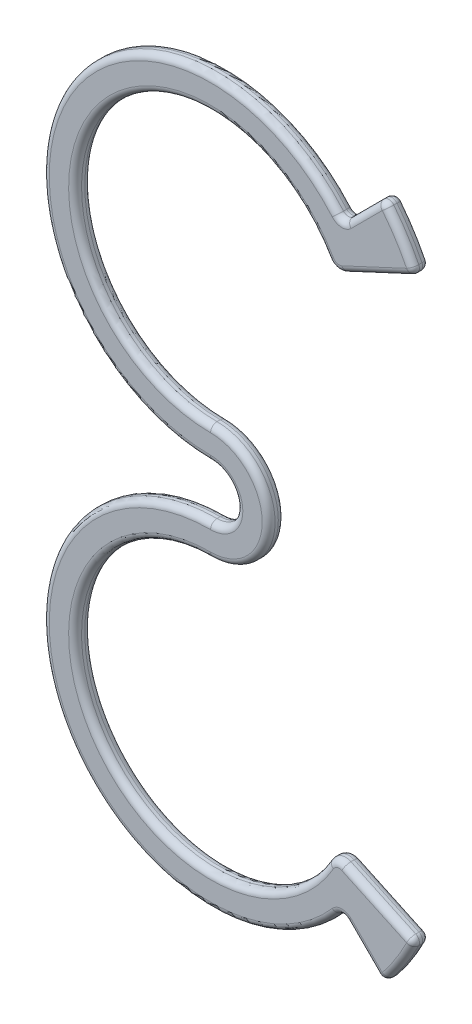
from build123d import *

# Parameters (mm, degrees)
BOSS_EXTRUDE1_DEPTH = 1.25
FILLET1_R           = 0.5


with BuildPart() as part:
    # Sketch1 → Boss-Extrude1 (new body)
    with BuildSketch(Plane.XY):
        with BuildLine():
            Line((10.537353283, 26.406687716), (13.347035358, 29.216369791))
            ThreePointArc((13.347035358, 29.216369791), (14.734825058, 27.339078818), (15.860386273, 25.293768672))
            Line((15.860386273, 25.293768672), (10.383060093, 22.739649528))
            ThreePointArc((10.383060093, 22.739649528), (9.659640671, 22.692270436), (9.094316454, 23.146130513))
            ThreePointArc((9.094316454, 23.146130513), (-9.092741746, 23.148858302), (0, 7.397949091))
            ThreePointArc((0, 7.397949091), (4.5, 2.897949091), (0, -1.602050909))
            ThreePointArc((0, -1.602050909), (-9.092741746, -17.352960119), (9.094316454, -17.35023233))
            ThreePointArc((9.094316454, -17.35023233), (9.659640671, -16.896372254), (10.383060093, -16.943751345))
            Line((10.383060093, -16.943751345), (15.860386273, -19.497870489))
            ThreePointArc((15.860386273, -19.497870489), (14.734825058, -21.543180636), (13.347035358, -23.420471609))
            Line((13.347035358, -23.420471609), (10.537353283, -20.610789533))
            ThreePointArc((10.537353283, -20.610789533), (10.166484929, -20.464642822), (9.806622118, -20.636109886))
            ThreePointArc((9.806622118, -20.636109886), (-11.83095023, -17.48987205), (0, 0.897949091))
            ThreePointArc((0, 0.897949091), (2, 2.897949091), (0, 4.897949091))
            ThreePointArc((0, 4.897949091), (-11.83095023, 23.285770232), (9.806622118, 26.432008069))
            ThreePointArc((9.806622118, 26.432008069), (10.166484929, 26.260541004), (10.537353283, 26.406687716))
        make_face()
    extrude(amount=BOSS_EXTRUDE1_DEPTH)

    # Fillet1
    fillet1_edges = [part.edges().sort_by_distance(p)[0] for p in [
        (10.166484929, 26.260541004, 1.25),
        (13.121723183, 24.0167091, 0),
        (9.659640671, 22.692270436, 0),
        (-9.092741746, 23.148858302, 0),
        (-11.83095023, 23.285770232, 1.25),
        (4.5, 2.897949091, 0),
        (-9.092741746, -17.352960119, 0),
        (9.659640671, -16.896372254, 0),
        (13.121723183, -18.220810917, 0),
        (14.734825058, -21.543180636, 0),
        (11.94219432, -22.015630571, 0),
        (10.166484929, -20.464642822, 0),
        (-11.83095023, -17.48987205, 0),
        (2, 2.897949091, 0),
        (-11.83095023, 23.285770232, 0),
        (2, 2.897949091, 1.25),
        (10.166484929, 26.260541004, 0),
        (11.94219432, 27.811528754, 0),
        (14.734825058, 27.339078818, 0),
        (-11.83095023, -17.48987205, 1.25),
        (15.860386273, 25.293768672, 0.625),
        (15.860386273, -19.497870489, 0.625),
        (13.347035358, -23.420471609, 0.625),
        (13.347035358, 29.216369791, 0.625),
        (10.166484929, -20.464642822, 1.25),
        (11.94219432, -22.015630571, 1.25),
        (14.734825058, -21.543180636, 1.25),
        (13.121723183, -18.220810917, 1.25),
        (9.659640671, -16.896372254, 1.25),
        (-9.092741746, -17.352960119, 1.25),
        (14.734825058, 27.339078818, 1.25),
        (4.5, 2.897949091, 1.25),
        (-9.092741746, 23.148858302, 1.25),
        (9.659640671, 22.692270436, 1.25),
        (13.121723183, 24.0167091, 1.25),
        (11.94219432, 27.811528754, 1.25),
    ]]
    fillet(fillet1_edges, radius=FILLET1_R)


solid = part.part
